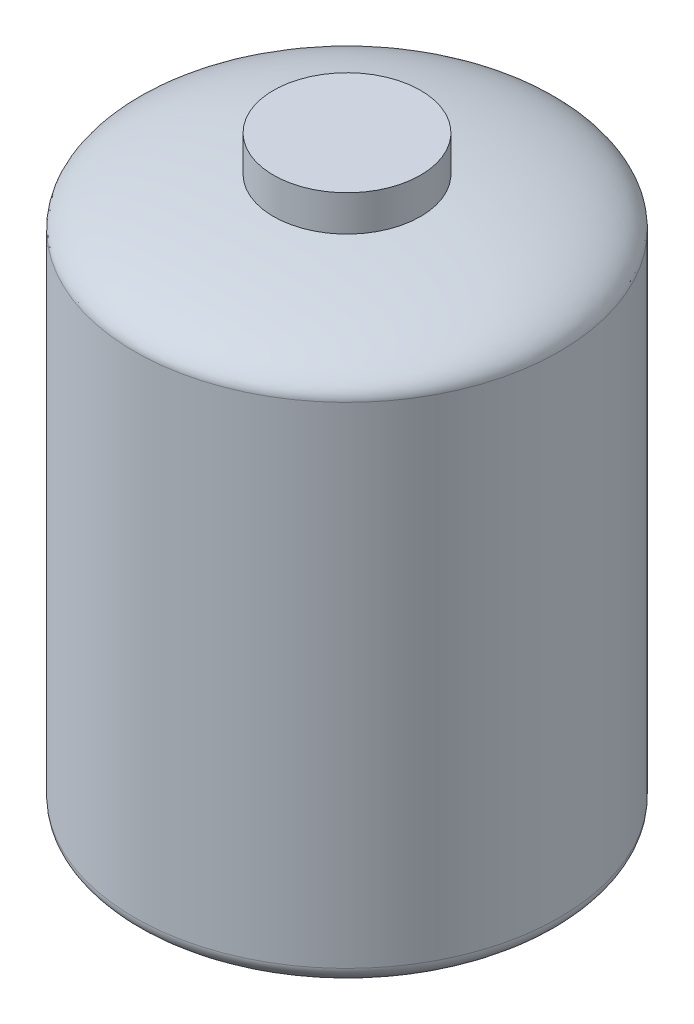
from build123d import *


with BuildPart() as part:
    # Sketch1 → Revolve1 (revolve)
    with BuildSketch(Plane.XY):
        with BuildLine():
            Line((0, 913.71416483), (-225, 913.71416483))
            Line((-225, 913.71416483), (-225, 804.131718079))
            add(Edge.make_bspline(
                [(-225, 804.131718079), (-650, 766.738632957), (-650, 658.71416483)],
                knots=[1.924264713, 1.924264713, 1.924264713, 3.141592654, 3.141592654, 3.141592654], degree=2, weights=[1, 0.820412654, 1]))
            Line((-650, 658.71416483), (-650, -841.28583517))
            add(Edge.make_bspline(
                [(-650, -841.28583517), (-650, -996.28583517), (0, -996.28583517)],
                knots=[3.141592654, 3.141592654, 3.141592654, 4.71238898, 4.71238898, 4.71238898], degree=2, weights=[1, 0.707106781, 1]))
            Line((0, -996.28583517), (0, 913.71416483))
        make_face()
    revolve(axis=Axis((0, -996.28583517, 0), (0, 1, 0)))


solid = part.part
